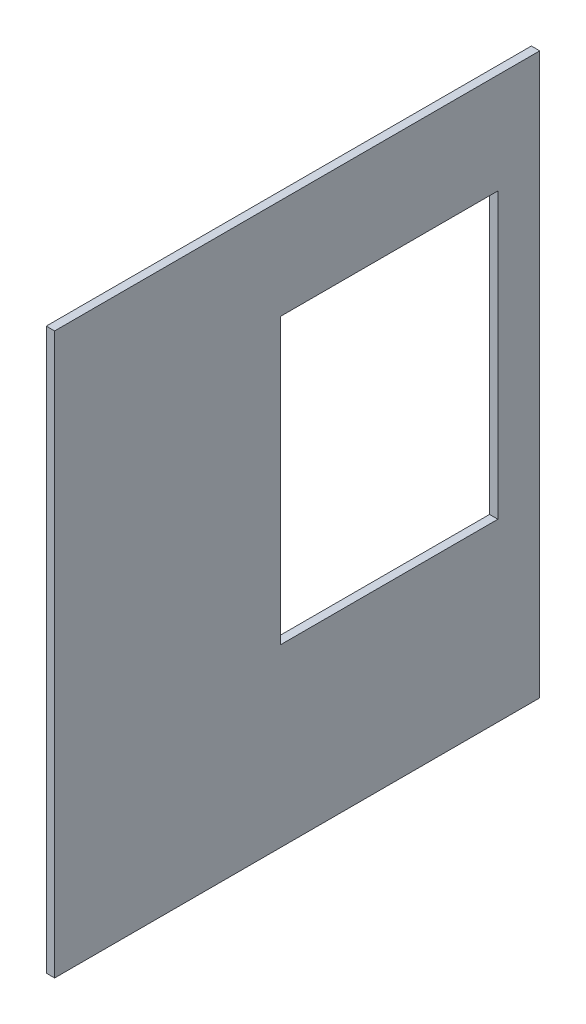
from build123d import *

# Parameters (mm, degrees)
ESQUISSE1_W        = 580
ESQUISSE1_H        = 670
ESQUISSE1_W_2      = 260
ESQUISSE1_H_2      = 340
BOSS_EXTRU_1_DEPTH = 10


with BuildPart() as part:
    # Esquisse1 → Boss.-Extru.1 (new body)
    with BuildSketch(Plane(origin=(0, 0, 0), x_dir=(0, 0, -1), z_dir=(1, 0, 0))):
        with Locations((225.408971833, -295.278255821)):
            Rectangle(ESQUISSE1_W, ESQUISSE1_H)
        with Locations((335.408971833, -250.278255821)):
            Rectangle(ESQUISSE1_W_2, ESQUISSE1_H_2, mode=Mode.SUBTRACT)
    extrude(amount=BOSS_EXTRU_1_DEPTH)


solid = part.part
